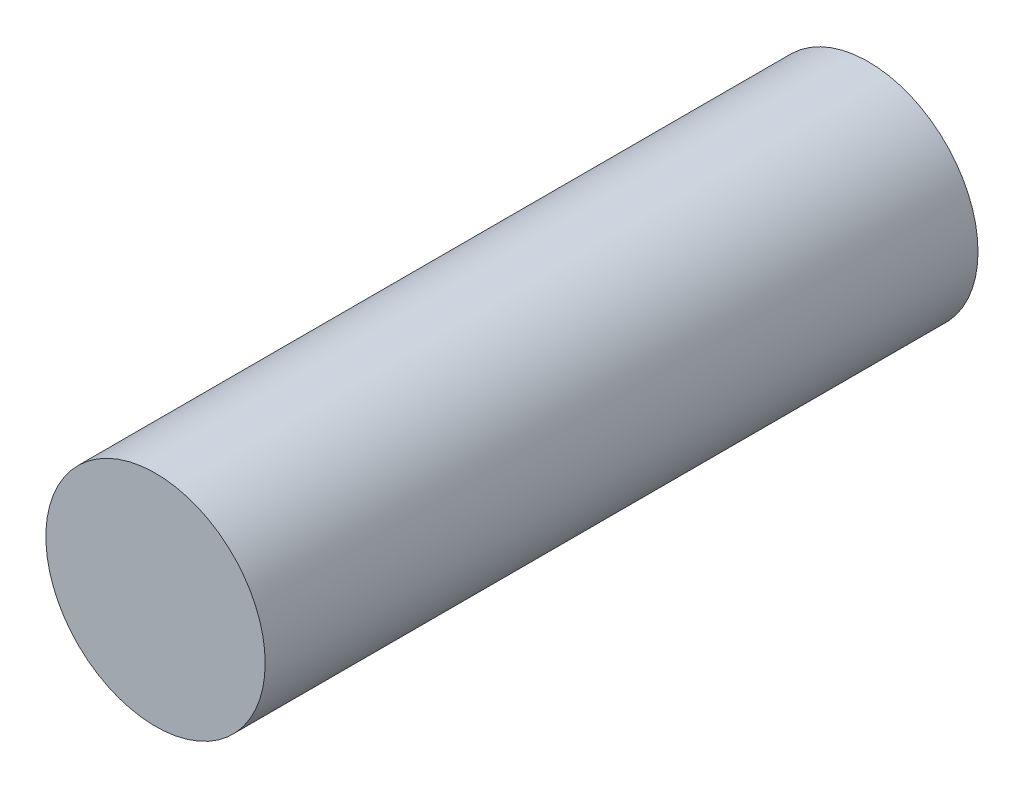
from build123d import *

# Parameters (mm, degrees)
SKETCH1_R           = 2
BOSS_EXTRUDE1_DEPTH = 13


with BuildPart() as part:
    # Sketch1 → Boss-Extrude1 (new body)
    with BuildSketch(Plane.XY):
        Circle(SKETCH1_R)
    extrude(amount=BOSS_EXTRUDE1_DEPTH)


solid = part.part
